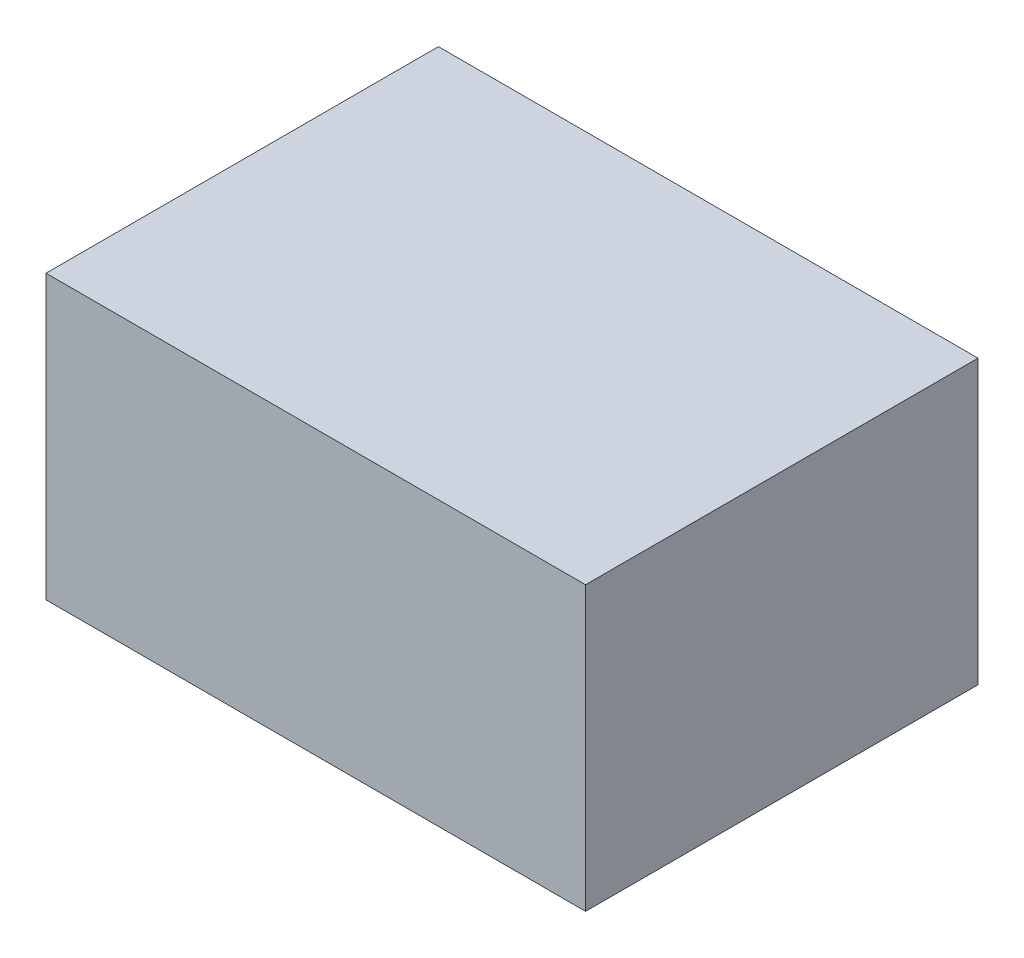
from build123d import *

# Parameters (mm, degrees)
ESQUISSE1_W        = 330
ESQUISSE1_H        = 173
BOSS_EXTRU_1_DEPTH = 240


with BuildPart() as part:
    # Esquisse1 → Boss.-Extru.1 (new body)
    with BuildSketch(Plane.XY):
        with Locations((165, 86.5)):
            Rectangle(ESQUISSE1_W, ESQUISSE1_H)
    extrude(amount=BOSS_EXTRU_1_DEPTH)


solid = part.part
